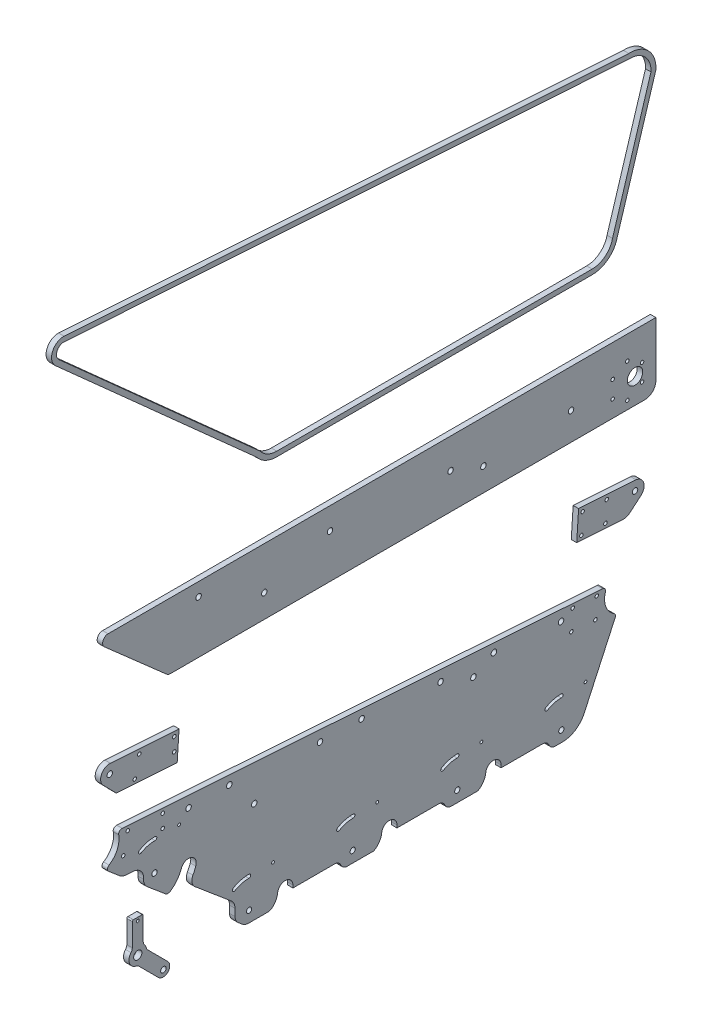
from build123d import *

# Parameters (mm, degrees)
SKETCH_1_R        = 3.75
SKETCH_1_R_2      = 1.3
SKETCH_1_R_3      = 2.5
EXTRUDE_2_DEPTH   = 5
SKETCH_1_R_4      = 1.6
SKETCH_1_R_5      = 2.4
EXTRUDE_2_2_DEPTH = 5
EXTRUDE_2_3_DEPTH = 5
EXTRUDE_2_4_DEPTH = 5
SKETCH_1_R_6      = 7
EXTRUDE_2_5_DEPTH = 5
EXTRUDE_2_6_DEPTH = 5


with BuildPart() as part:
    # 草图1 → 凸台-拉伸2 (new body)
    with BuildSketch(Plane(origin=(0, 0, 0), x_dir=(0, 0, -1), z_dir=(1, 0, 0))):
        with BuildLine():
            Line((-230.046495274, 110.964324565), (-222.046495274, 110.964324565))
            ThreePointArc((-222.046495274, 110.964324565), (-221.339388493, 110.671431346), (-221.046495274, 109.964324565))
            Line((-221.046495274, 109.964324565), (-221.046495274, 89.270948428))
            ThreePointArc((-221.046495274, 89.270948428), (-220.74919499, 87.572532876), (-219.89264912, 86.076093096))
            ThreePointArc((-219.89264912, 86.076093096), (-218.915806568, 84.591069466), (-218.290987907, 82.927002703))
            ThreePointArc((-218.290987907, 82.927002703), (-217.791235571, 81.68390581), (-216.979329708, 80.618142633))
            Line((-216.979329708, 80.618142633), (-198.59455309, 62.233366015))
            ThreePointArc((-198.59455309, 62.233366015), (-198.59455309, 53.748084641), (-207.079834464, 53.748084641))
            Line((-207.079834464, 53.748084641), (-225.090001091, 71.758251268))
            ThreePointArc((-225.090001091, 71.758251268), (-226.261139721, 72.62835409), (-227.633596642, 73.123335517))
            ThreePointArc((-227.633596642, 73.123335517), (-233.591298078, 78.304258655), (-232.200341428, 86.076093096))
            ThreePointArc((-232.200341428, 86.076093096), (-231.343795558, 87.572532876), (-231.046495274, 89.270948428))
            Line((-231.046495274, 89.270948428), (-231.046495274, 109.964324565))
            ThreePointArc((-231.046495274, 109.964324565), (-230.753602055, 110.671431346), (-230.046495274, 110.964324565))
        make_face()
        with Locations((-226.046495274, 80.964324565)):
            Circle(SKETCH_1_R, mode=Mode.SUBTRACT)
        with Locations((-226.046495274, 107.964324565)):
            Circle(SKETCH_1_R_2, mode=Mode.SUBTRACT)
        with Locations((-202.59441797, 57.747949522)):
            Circle(SKETCH_1_R_3, mode=Mode.SUBTRACT)
    extrude(amount=EXTRUDE_2_DEPTH)


with BuildPart() as body_2:
    # 草图1 → Extrude 2 2 (new body)
    with BuildSketch(Plane(origin=(0, 0, 0), x_dir=(0, 0, -1), z_dir=(1, 0, 0))):
        with BuildLine():
            Line((105.583383663, 65.605504458), (105.583383663, 63.205605904))
            Line((105.583383663, 63.205605904), (143.690315151, 63.205605904))
            ThreePointArc((143.690315151, 63.205605904), (146.853831621, 62.303856932), (149.066448849, 59.869660419))
            ThreePointArc((149.066448849, 59.869660419), (149.549988064, 58.982807559), (150.101340885, 58.136445796))
            ThreePointArc((150.101340885, 58.136445796), (152.241303504, 56.275666188), (154.996811444, 55.605504458))
            Line((154.996811444, 55.605504458), (161.488211202, 55.605504458))
            ThreePointArc((161.488211202, 55.605504458), (173.356454193, 59.081336236), (181.474513898, 68.410521884))
            Line((181.474513898, 68.410521884), (209.741886311, 129.852754854))
            ThreePointArc((209.741886311, 129.852754854), (209.895771417, 131.94904652), (208.636206854, 133.631787286))
            ThreePointArc((208.636206854, 133.631787286), (201.216960209, 142.86213505), (200.859321938, 154.699222338))
            ThreePointArc((200.859321938, 154.699222338), (200.455075853, 157.272313119), (198.190666273, 158.559426291))
            Line((198.190666273, 158.559426291), (-240.271926899, 188.341228152))
            ThreePointArc((-240.271926899, 188.341228152), (-242.707724178, 187.352111101), (-243.429098266, 184.824052488))
            ThreePointArc((-243.429098266, 184.824052488), (-244.8174313, 173.697288647), (-252.241283056, 165.293791323))
            ThreePointArc((-252.241283056, 165.293791323), (-253.670979066, 162.960137704), (-252.611229502, 160.436865869))
            Line((-252.611229502, 160.436865869), (-242.604694099, 152.016430764))
            ThreePointArc((-242.604694099, 152.016430764), (-239.902895117, 150.392279376), (-236.829746492, 149.689895579))
            Line((-236.829746492, 149.689895579), (-229.987782089, 149.234810912))
            ThreePointArc((-229.987782089, 149.234810912), (-223.011471033, 145.709041862), (-220.703186208, 138.240990944))
            ThreePointArc((-220.703186208, 138.240990944), (-219.905687706, 133.93271486), (-217.1391735, 130.535120738))
            Line((-217.1391735, 130.535120738), (-200.324649993, 116.385807483))
            ThreePointArc((-200.324649993, 116.385807483), (-198.617485499, 115.975161078), (-196.88555004, 116.264022025))
            ThreePointArc((-196.88555004, 116.264022025), (-190.452103552, 122.024221827), (-186.260054681, 129.573782194))
            ThreePointArc((-186.260054681, 129.573782194), (-177.326176643, 133.838266125), (-173.061692712, 124.904388087))
            ThreePointArc((-173.061692712, 124.904388087), (-174.265890201, 121.894514848), (-175.709869551, 118.992041396))
            ThreePointArc((-175.709869551, 118.992041396), (-176.56174822, 113.673382999), (-173.848478673, 109.020212813))
            Line((-173.848478673, 109.020212813), (-140.824521758, 81.230765727))
            ThreePointArc((-140.824521758, 81.230765727), (-138.197099711, 77.799171277), (-137.263140357, 73.579348175))
            Line((-137.263140357, 73.579348175), (-137.263140357, 67.043583636))
            ThreePointArc((-137.263140357, 67.043583636), (-136.515972873, 63.667725155), (-134.414035235, 60.922449595))
            Line((-134.414035235, 60.922449595), (-130.886542183, 57.954086907))
            ThreePointArc((-130.886542183, 57.954086907), (-127.874716873, 56.210980108), (-124.447923585, 55.605504458))
            Line((-124.447923585, 55.605504458), (-107.321286464, 55.605504458))
            ThreePointArc((-107.321286464, 55.605504458), (-105.415823076, 55.916110002), (-103.707642186, 56.815768032))
            ThreePointArc((-103.707642186, 56.815768032), (-101.737263428, 58.669981042), (-100.213146176, 60.905504458))
            ThreePointArc((-100.213146176, 60.905504458), (-99.065771873, 63.16028479), (-98.416616337, 65.605504458))
            ThreePointArc((-98.416616337, 65.605504458), (-91.416616337, 72.605504458), (-84.416616337, 65.605504458))
            Line((-84.416616337, 65.605504458), (-84.416616337, 63.201412325))
            Line((-84.416616337, 63.201412325), (-46.25623166, 63.201412325))
            ThreePointArc((-46.25623166, 63.201412325), (-43.126550078, 62.320503377), (-40.915856667, 59.936443391))
            ThreePointArc((-40.915856667, 59.936443391), (-40.30376406, 58.873901085), (-39.590008261, 57.876802208))
            ThreePointArc((-39.590008261, 57.876802208), (-37.499630602, 56.203087707), (-34.88928709, 55.605504458))
            Line((-34.88928709, 55.605504458), (-10.664100691, 55.605504458))
            ThreePointArc((-10.664100691, 55.605504458), (-7.524907263, 57.830004825), (-5.21314619, 60.905504458))
            ThreePointArc((-5.21314619, 60.905504458), (-4.065769181, 63.160291849), (-3.416614019, 65.605519397))
            ThreePointArc((-3.416614019, 65.605519397), (3.583391133, 72.605502141), (10.583381346, 65.605504458))
            Line((10.583381346, 65.605504458), (10.583381346, 63.181022103))
            Line((10.583381346, 63.181022103), (48.717102341, 63.181022103))
            ThreePointArc((48.717102341, 63.181022103), (51.87604368, 62.282109204), (54.088447314, 59.854718642))
            ThreePointArc((54.088447314, 59.854718642), (54.571581261, 58.972141946), (55.122004847, 58.129886693))
            ThreePointArc((55.122004847, 58.129886693), (57.260885764, 56.27382055), (60.012820847, 55.605504458))
            Line((60.012820847, 55.605504458), (84.335899309, 55.605504458))
            ThreePointArc((84.335899309, 55.605504458), (87.47509274, 57.830004824), (89.786853817, 60.905504458))
            ThreePointArc((89.786853817, 60.905504458), (90.934228135, 63.160284803), (91.583383681, 65.605504488))
            ThreePointArc((91.583383681, 65.605504488), (98.583383687, 72.605504464), (105.583383663, 65.605504458))
        make_face()
        with Locations((160.339126304, 151.540653446)):
            Circle(SKETCH_1_R_3, mode=Mode.SUBTRACT)
        with Locations((-179.660873696, 174.155326316)):
            Circle(SKETCH_1_R_3, mode=Mode.SUBTRACT)
        with Locations((192.942417712, 155.385344063)):
            Circle(SKETCH_1_R_4, mode=Mode.SUBTRACT)
        with Locations((50.339126304, 158.857165257)):
            Circle(SKETCH_1_R_3, mode=Mode.SUBTRACT)
        with Locations((80.339126304, 147.540653446)):
            Circle(SKETCH_1_R_3, mode=Mode.SUBTRACT)
        with Locations((-119.660873696, 147.540653446)):
            Circle(SKETCH_1_R_3, mode=Mode.SUBTRACT)
        with Locations((170.990921691, 156.845420244)):
            Circle(SKETCH_1_R_4, mode=Mode.SUBTRACT)
        with Locations((-59.660873696, 166.173677068)):
            Circle(SKETCH_1_R_3, mode=Mode.SUBTRACT)
        with Locations((169.783040487, 138.685546264)):
            Circle(SKETCH_1_R_4, mode=Mode.SUBTRACT)
        with Locations((191.734536508, 137.225470083)):
            Circle(SKETCH_1_R_4, mode=Mode.SUBTRACT)
        with Locations((-235.168216636, 183.905166746)):
            Circle(SKETCH_1_R_4, mode=Mode.SUBTRACT)
        with Locations((-203.241831947, 181.736308834)):
            Circle(SKETCH_1_R_4, mode=Mode.SUBTRACT)
        with Locations((-239.325744248, 166.189334324)):
            Circle(SKETCH_1_R_4, mode=Mode.SUBTRACT)
        with Locations((-188.283217114, 165.245514101)):
            Circle(SKETCH_1_R_2, mode=Mode.SUBTRACT)
        with Locations((-203.325744248, 169.736602224)):
            Circle(SKETCH_1_R_4, mode=Mode.SUBTRACT)
        with Locations((-210.771298338, 138.245514108)):
            Circle(SKETCH_1_R_5, mode=Mode.SUBTRACT)
        with Locations((-102.569781686, 92.605504458)):
            Circle(SKETCH_1_R_2, mode=Mode.SUBTRACT)
        with Locations((87.641536467, 92.605504452)):
            Circle(SKETCH_1_R_2, mode=Mode.SUBTRACT)
        with Locations((65.641536467, 65.605504458)):
            Circle(SKETCH_1_R_5, mode=Mode.SUBTRACT)
        with Locations((-21.723580833, 165.654744888)):
            Circle(SKETCH_1_R_3, mode=Mode.SUBTRACT)
        with Locations((-29.846544757, 65.605504458)):
            Circle(SKETCH_1_R_5, mode=Mode.SUBTRACT)
        with Locations((-7.358463533, 92.605504452)):
            Circle(SKETCH_1_R_2, mode=Mode.SUBTRACT)
        with Locations((-142.488642225, 173.687281234)):
            Circle(SKETCH_1_R_3, mode=Mode.SUBTRACT)
        with Locations((99.041480559, 157.622208542)):
            Circle(SKETCH_1_R_3, mode=Mode.SUBTRACT)
        with Locations((182.641536467, 92.605504452)):
            Circle(SKETCH_1_R_2, mode=Mode.SUBTRACT)
        with Locations((-124.416616337, 65.605504458)):
            Circle(SKETCH_1_R_5, mode=Mode.SUBTRACT)
        with Locations((160.641536467, 65.605504458)):
            Circle(SKETCH_1_R_5, mode=Mode.SUBTRACT)
        with BuildLine():
            ThreePointArc((-210.252211221, 166.845213647), (-217.715946718, 165.934353364), (-224.632475828, 162.985007827))
            ThreePointArc((-224.632475828, 162.985007827), (-225.173649162, 160.787934451), (-222.976575785, 160.246761116))
            ThreePointArc((-222.976575785, 160.246761116), (-216.886317088, 162.84376852), (-210.314223007, 163.645814556))
            ThreePointArc((-210.314223007, 163.645814556), (-208.683517569, 165.214508208), (-210.252211221, 166.845213647))
        make_face(mode=Mode.SUBTRACT)
        with BuildLine():
            ThreePointArc((-29.32745764, 94.205203997), (-36.791193137, 93.294343714), (-43.707722246, 90.344998178))
            ThreePointArc((-43.707722246, 90.344998178), (-44.248895581, 88.147924801), (-42.051822204, 87.606751467))
            ThreePointArc((-42.051822204, 87.606751467), (-35.961563507, 90.20375887), (-29.389469426, 91.005804907))
            ThreePointArc((-29.389469426, 91.005804907), (-27.758763988, 92.574498559), (-29.32745764, 94.205203997))
        make_face(mode=Mode.SUBTRACT)
        with BuildLine():
            ThreePointArc((-124.538775792, 94.205204003), (-132.002511289, 93.294343721), (-138.919040399, 90.344998184))
            ThreePointArc((-138.919040399, 90.344998184), (-139.460213733, 88.147924807), (-137.263140357, 87.606751473))
            ThreePointArc((-137.263140357, 87.606751473), (-131.17288166, 90.203758877), (-124.600787579, 91.005804913))
            ThreePointArc((-124.600787579, 91.005804913), (-122.97008214, 92.574498565), (-124.538775792, 94.205204003))
        make_face(mode=Mode.SUBTRACT)
        with BuildLine():
            ThreePointArc((65.67254236, 94.205204009), (58.20880686, 93.294343726), (51.292277747, 90.344998188))
            ThreePointArc((51.292277747, 90.344998188), (50.751104411, 88.147924803), (52.948177796, 87.606751467))
            ThreePointArc((52.948177796, 87.606751467), (59.038436493, 90.203758871), (65.610530574, 91.005804907))
            ThreePointArc((65.610530574, 91.005804907), (67.241236018, 92.574498565), (65.67254236, 94.205204009))
        make_face(mode=Mode.SUBTRACT)
        with BuildLine():
            ThreePointArc((160.67254236, 94.205204), (153.208806863, 93.294343717), (146.292277752, 90.34499818))
            ThreePointArc((146.292277752, 90.34499818), (145.751104417, 88.147924801), (147.948177796, 87.606751467))
            ThreePointArc((147.948177796, 87.606751467), (154.038436493, 90.20375887), (160.610530574, 91.005804907))
            ThreePointArc((160.610530574, 91.005804907), (162.241236014, 92.57449856), (160.67254236, 94.205204))
        make_face(mode=Mode.SUBTRACT)
    extrude(amount=EXTRUDE_2_2_DEPTH)


with BuildPart() as body_3:
    # 草图1 → Extrude 2 3 (new body)
    with BuildSketch(Plane(origin=(0, 0, 0), x_dir=(0, 0, -1), z_dir=(1, 0, 0))):
        with BuildLine():
            Line((-190.050545595, 215.109927768), (-188.328019491, 241.007223677))
            Line((-188.328019491, 241.007223677), (-251.036184185, 245.178178473))
            ThreePointArc((-251.036184185, 245.178178473), (-259.168077639, 240.345820631), (-257.56238395, 231.023743543))
            Line((-257.56238395, 231.023743543), (-245.641349699, 218.807480266))
            Line((-245.641349699, 218.807480266), (-190.050545595, 215.109927768))
        make_face()
        with Locations((-228.790003439, 221.534209043)):
            Circle(SKETCH_1_R_4, mode=Mode.SUBTRACT)
        with Locations((-224.632475828, 239.250041465)):
            Circle(SKETCH_1_R_4, mode=Mode.SUBTRACT)
        with Locations((-251.590003439, 236.851790223)):
            Circle(SKETCH_1_R_3, mode=Mode.SUBTRACT)
        with Locations((-192.706091138, 237.081183553)):
            Circle(SKETCH_1_R_4, mode=Mode.SUBTRACT)
        with Locations((-192.790003439, 225.081476943)):
            Circle(SKETCH_1_R_4, mode=Mode.SUBTRACT)
    extrude(amount=EXTRUDE_2_3_DEPTH)


with BuildPart() as body_4:
    # 草图1 → Extrude 2 4 (new body)
    with BuildSketch(Plane(origin=(0, 0, 0), x_dir=(0, 0, -1), z_dir=(1, 0, 0))):
        with BuildLine():
            Line((174.651176426, 206.647648012), (216.237337598, 203.881596745))
            ThreePointArc((216.237337598, 203.881596745), (220.031983084, 204.362339432), (223.368552979, 206.232566488))
            Line((223.368552979, 206.232566488), (233.420459931, 214.756402778))
            ThreePointArc((233.420459931, 214.756402778), (235.825149484, 223.565263901), (228.726521319, 229.308785844))
            Line((228.726521319, 229.308785844), (176.389994423, 232.789884182))
            Line((176.389994423, 232.789884182), (174.651176426, 206.647648012))
        make_face()
        with Locations((180.115707121, 228.533234691)):
            Circle(SKETCH_1_R_4, mode=Mode.SUBTRACT)
        with Locations((200.859321938, 208.913284529)):
            Circle(SKETCH_1_R_4, mode=Mode.SUBTRACT)
        with Locations((202.067203142, 227.07315851)):
            Circle(SKETCH_1_R_4, mode=Mode.SUBTRACT)
        with Locations((227.878322136, 221.001977904)):
            Circle(SKETCH_1_R_3, mode=Mode.SUBTRACT)
        with Locations((178.907825917, 210.37336071)):
            Circle(SKETCH_1_R_4, mode=Mode.SUBTRACT)
    extrude(amount=EXTRUDE_2_4_DEPTH)


with BuildPart() as body_5:
    # 草图1 → Extrude 2 5 (new body)
    with BuildSketch(Plane(origin=(0, 0, 0), x_dir=(0, 0, -1), z_dir=(1, 0, 0))):
        with BuildLine():
            Line((246.878322136, 348.578811266), (246.878322136, 298.578811266))
            ThreePointArc((246.878322136, 298.578811266), (243.949389948, 291.507743454), (236.878322136, 288.578811266))
            Line((236.878322136, 288.578811266), (-195.93501426, 288.578811266))
            ThreePointArc((-195.93501426, 288.578811266), (-198.053523564, 288.965263517), (-199.899131971, 290.07483849))
            Line((-199.899131971, 290.07483849), (-256.42510929, 339.825500619))
            ThreePointArc((-256.42510929, 339.825500619), (-257.799634322, 345.344235686), (-253.121677864, 348.578811266))
            Line((-253.121677864, 348.578811266), (246.878322136, 348.578811266))
        make_face()
        with Locations((-170.536088266, 336.426863387)):
            Circle(SKETCH_1_R_3, mode=Mode.SUBTRACT)
        with Locations((89.463911734, 309.812190517)):
            Circle(SKETCH_1_R_3, mode=Mode.SUBTRACT)
        with Locations((59.463911734, 321.128702328)):
            Circle(SKETCH_1_R_3, mode=Mode.SUBTRACT)
        with Locations((-110.536088266, 309.812190517)):
            Circle(SKETCH_1_R_3, mode=Mode.SUBTRACT)
        with Locations((227.878322136, 311.585700529)):
            Circle(SKETCH_1_R_6, mode=Mode.SUBTRACT)
        with Locations((169.463911734, 313.812190517)):
            Circle(SKETCH_1_R_3, mode=Mode.SUBTRACT)
        with Locations((-50.536088266, 328.445214139)):
            Circle(SKETCH_1_R_3, mode=Mode.SUBTRACT)
        with Locations((234.301715894, 319.335700529)):
            Circle(SKETCH_1_R_4, mode=Mode.SUBTRACT)
        with Locations((220.878322136, 327.085700529)):
            Circle(SKETCH_1_R_4, mode=Mode.SUBTRACT)
        with Locations((207.454928377, 319.335700529)):
            Circle(SKETCH_1_R_4, mode=Mode.SUBTRACT)
        with Locations((207.454928377, 303.835700529)):
            Circle(SKETCH_1_R_4, mode=Mode.SUBTRACT)
        with Locations((220.878322136, 296.085700529)):
            Circle(SKETCH_1_R_4, mode=Mode.SUBTRACT)
        with Locations((234.301715894, 303.835700529)):
            Circle(SKETCH_1_R_4, mode=Mode.SUBTRACT)
    extrude(amount=EXTRUDE_2_5_DEPTH)


with BuildPart() as body_6:
    # 草图1 → Extrude 2 6 (new body)
    with BuildSketch(Plane(origin=(0, 0, 0), x_dir=(0, 0, -1), z_dir=(1, 0, 0))):
        with BuildLine():
            Line((-293.346698851, 603.927011141), (222.271860635, 569.63129041))
            ThreePointArc((222.271860635, 569.63129041), (240.389801377, 562.469351049), (246.878322136, 544.0994776))
            Line((246.878322136, 544.0994776), (211.699335237, 429.789658268))
            ThreePointArc((211.699335237, 429.789658268), (203.454800149, 416.590178698), (188.769993718, 411.437016575))
            Line((188.769993718, 411.437016575), (-99.176213419, 411.437016575))
            ThreePointArc((-99.176213419, 411.437016575), (-109.578063069, 413.864486498), (-117.83096147, 420.645397522))
            Line((-117.83096147, 420.645397522), (-300.989057463, 584.351224628))
            ThreePointArc((-300.989057463, 584.351224628), (-303.962462375, 596.791713692), (-293.346698851, 603.927011141))
        make_face()
        with BuildLine():
            Line((-293.515227891, 599.428277448), (222.251094006, 565.122728485))
            ThreePointArc((222.251094006, 565.122728485), (236.90401913, 559.596830962), (242.429916653, 544.943905838))
            Line((242.429916653, 544.943905838), (207.344198437, 430.937151695))
            ThreePointArc((207.344198437, 430.937151695), (200.70738387, 420.155314496), (188.769993718, 415.937016575))
            Line((188.769993718, 415.937016575), (-99.176213419, 415.937016575))
            ThreePointArc((-99.176213419, 415.937016575), (-107.765653096, 417.989405356), (-114.499422286, 423.703171729))
            Line((-114.499422286, 423.703171729), (-297.990235663, 587.706380036))
            ThreePointArc((-297.990235663, 587.706380036), (-299.788755079, 595.108140354), (-293.515227891, 599.428277448))
        make_face(mode=Mode.SUBTRACT)
    extrude(amount=EXTRUDE_2_6_DEPTH)


solid = Compound([part.part, body_2.part, body_3.part, body_4.part, body_5.part, body_6.part])
